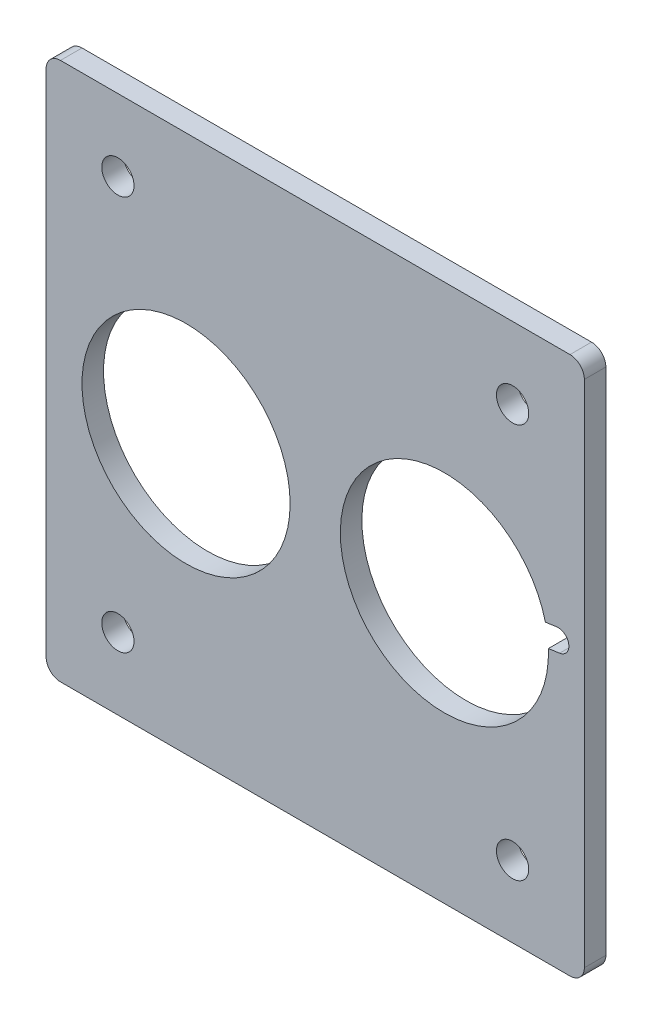
from build123d import *

# Parameters (mm, degrees)
SKIZZE1_W                       = 75
SKIZZE1_H                       = 75
AUFSATZ_LINEAR_AUSTRAGEN1_DEPTH = 3
SKIZZE2_R                       = 14.5
SCHNITT_LINEAR_AUSTRAGEN1_DEPTH = 4
VERRUNDUNG1_R                   = 2
DURCHGANGSLOCH_F_R_M41_D        = 4.5
SCHNITT_LINEAR_AUSTRAGEN2_DEPTH = 4


with BuildPart() as part:
    # Skizze1 → Aufsatz-Linear austragen1 (new body)
    with BuildSketch(Plane.XY):
        Rectangle(SKIZZE1_W, SKIZZE1_H)
    extrude(amount=AUFSATZ_LINEAR_AUSTRAGEN1_DEPTH)

    # Skizze2 → Schnitt-Linear austragen1 (cut, through all)
    with BuildSketch(Plane.XY.offset(3)):
        with Locations((-18, 0)):
            Circle(SKIZZE2_R)
        with Locations((18, 0)):
            Circle(SKIZZE2_R)
    extrude(amount=-SCHNITT_LINEAR_AUSTRAGEN1_DEPTH, mode=Mode.SUBTRACT)

    # Verrundung1
    verrundung1_edges = [part.edges().sort_by_distance(p)[0] for p in [
        (37.5, -37.5, 1.5),
        (-37.5, -37.5, 1.5),
        (-37.5, 37.5, 1.5),
        (37.5, 37.5, 1.5),
    ]]
    fillet(verrundung1_edges, radius=VERRUNDUNG1_R)

    # Durchgangsloch für M41 (through all)
    with Locations(Plane.XY.offset(3)):
        with Locations((27.5, 27.5), (-27.5, 27.5)):
            durchgangsloch_f_r_m41 = Hole(DURCHGANGSLOCH_F_R_M41_D / 2)

    # Spiegeln1: Durchgangsloch für M41 across plane
    add(durchgangsloch_f_r_m41.mirror(Plane.ZX), mode=Mode.SUBTRACT)

    # Skizze6 → Schnitt-Linear austragen2 (cut, through all)
    with BuildSketch(Plane.XY.offset(3)):
        with BuildLine():
            Line((17.791240349, 1.485402103), (33.635529448, 3.712171718))
            ThreePointArc((33.635529448, 3.712171718), (35.329691203, 2.435529267), (34.053048751, 0.741367512))
            Line((34.053048751, 0.741367512), (18.208759651, -1.485402103))
            ThreePointArc((18.208759651, -1.485402103), (16.514597897, -0.208759651), (17.791240349, 1.485402103))
        make_face()
    extrude(amount=-SCHNITT_LINEAR_AUSTRAGEN2_DEPTH, mode=Mode.SUBTRACT)


solid = part.part
